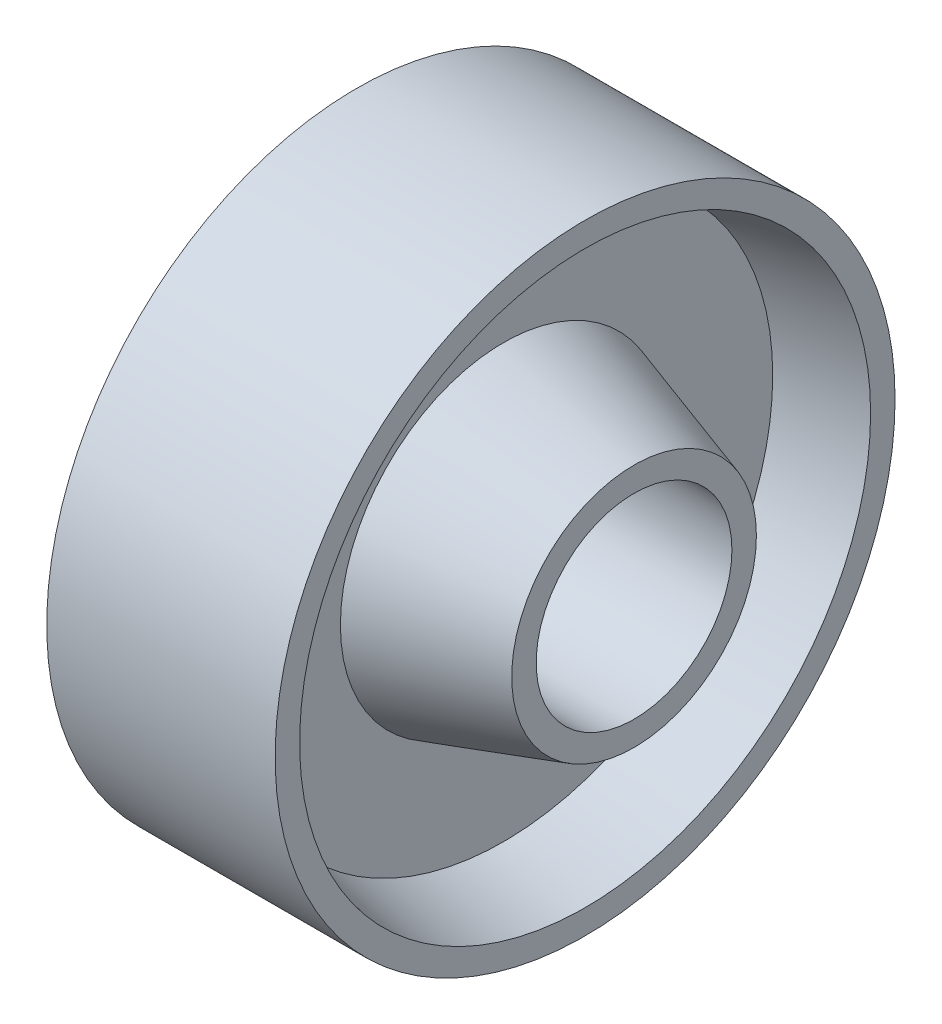
from build123d import *


with BuildPart() as part:
    # Sketch1 → Revolve1 (revolve)
    with BuildSketch(Plane.XY):
        Polygon((20, 12), (20, 15), (4, 20), (4, 33), (14, 35), (14, 38), (-14, 38), (-14, 35), (-4, 33), (-4, 20), (-20, 15), (-20, 12), align=None)
    revolve(axis=Axis((24.279883382, 0, 0), (-1, 0, 0)))


solid = part.part
